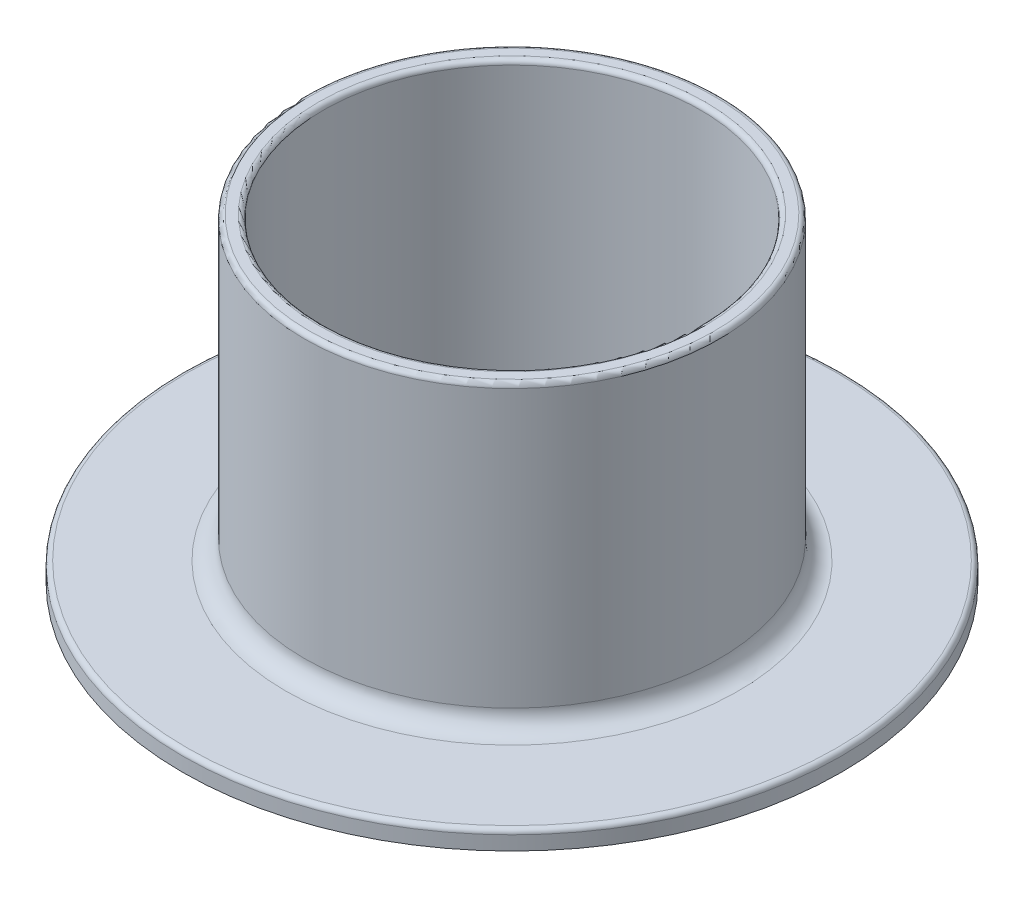
from build123d import *


with BuildPart() as part:
    # Sketch1 → Revolve1 (revolve)
    with BuildSketch(Plane.XY):
        with BuildLine():
            Line((22.125, 33.5), (22.125, 4))
            ThreePointArc((22.125, 4), (22.710786438, 2.585786438), (24.125, 2))
            Line((24.125, 2), (34.625, 2))
            ThreePointArc((34.625, 2), (34.978553391, 1.853553391), (35.125, 1.5))
            Line((35.125, 1.5), (35.125, 0))
            Line((35.125, 0), (20.125, 0))
            Line((20.125, 0), (20.125, 33.5))
            ThreePointArc((20.125, 33.5), (20.271446609, 33.853553391), (20.625, 34))
            Line((20.625, 34), (21.625, 34))
            ThreePointArc((21.625, 34), (21.978553391, 33.853553391), (22.125, 33.5))
        make_face()
    revolve(axis=Axis((0, 40.764727394, 0), (0, -1, 0)))


solid = part.part
